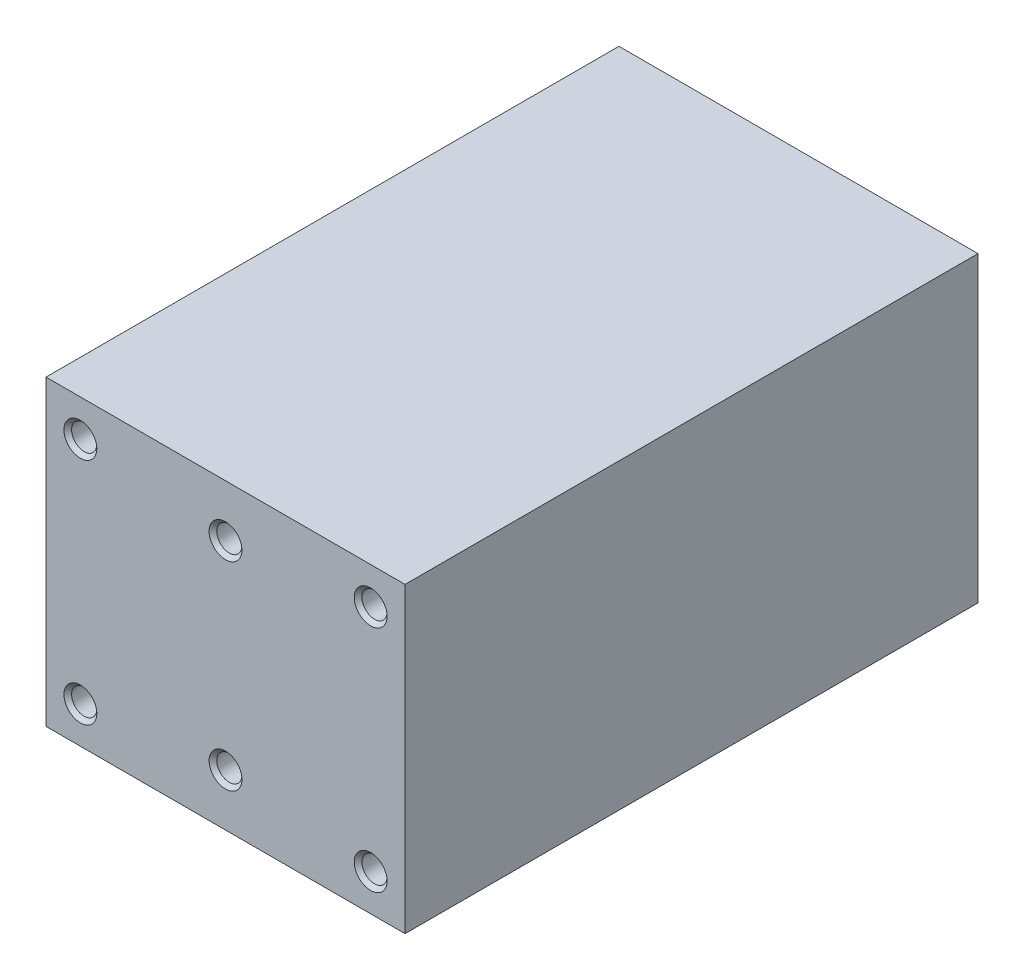
from build123d import *

# Parameters (mm, degrees)
SZKIC1_W                       = 47
SZKIC1_H                       = 39.6
DODANIE_WYCI_GNI_CIE1_DEPTH    = 75
OTW_R_GWINTOWANY_M4X0_72_D     = 3.3
OTW_R_GWINTOWANY_M4X0_72_DEPTH = 15
OTW_R_GWINTOWANY_M4X0_72_TIP   = 0.991420021
SFAZOWANIE1_SIZE               = 0.5


with BuildPart() as part:
    # Szkic1 → Dodanie-wyciągnięcie1 (new body)
    with BuildSketch(Plane.XY):
        with Locations((23.5, 19.8)):
            Rectangle(SZKIC1_W, SZKIC1_H)
    extrude(amount=DODANIE_WYCI_GNI_CIE1_DEPTH)

    # Otwór gwintowany M4x0.72
    with Locations(Plane.XY.offset(75)):
        with Locations((4.5, 34.8), (23.5, 32.8), (42.5, 34.8), (42.5, 4.8), (23.5, 6.8), (4.5, 4.8)):
            Hole(OTW_R_GWINTOWANY_M4X0_72_D / 2, depth=OTW_R_GWINTOWANY_M4X0_72_DEPTH)
            with Locations((0, 0, -(OTW_R_GWINTOWANY_M4X0_72_DEPTH + OTW_R_GWINTOWANY_M4X0_72_TIP / 2))):  # 118° drill point
                Cone(0, OTW_R_GWINTOWANY_M4X0_72_D / 2, OTW_R_GWINTOWANY_M4X0_72_TIP, mode=Mode.SUBTRACT)

    # Sfazowanie1
    sfazowanie1_edges = [part.edges().sort_by_distance(p)[0] for p in [
        (6.15, 4.8, 75),
        (25.15, 6.8, 75),
        (44.15, 4.8, 75),
        (44.15, 34.8, 75),
        (25.15, 32.8, 75),
        (6.15, 34.8, 75),
    ]]
    chamfer(sfazowanie1_edges, length=SFAZOWANIE1_SIZE)


solid = part.part
